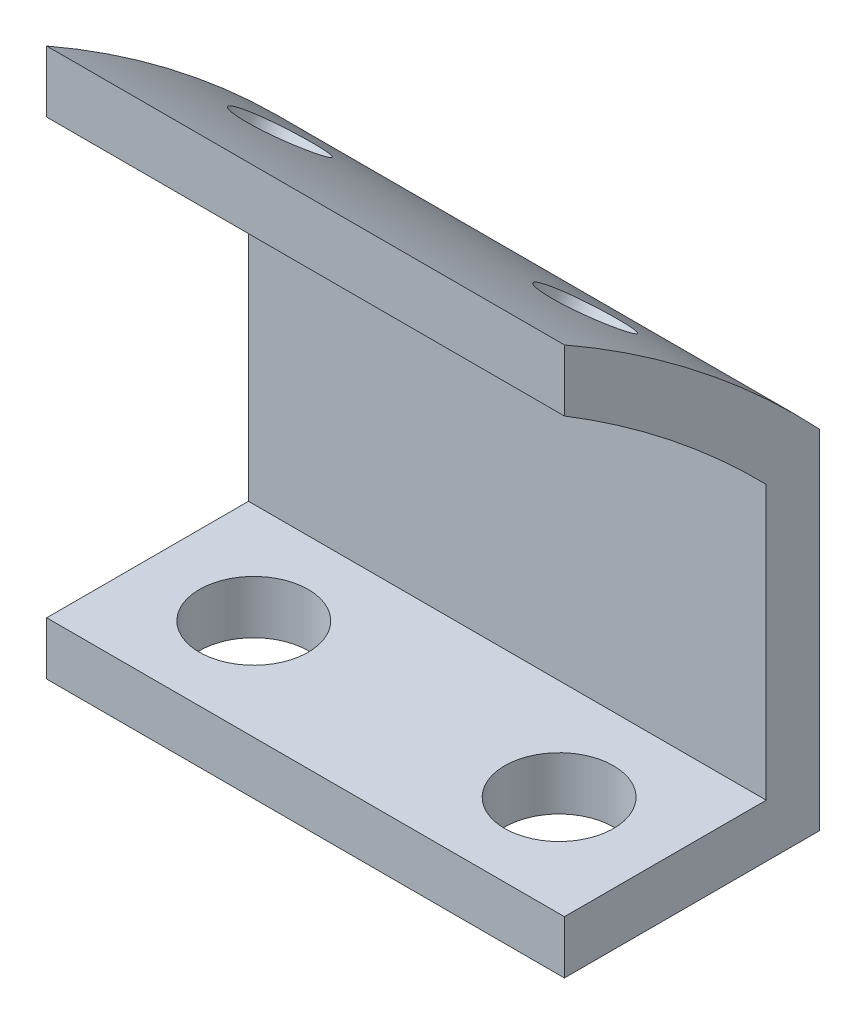
from build123d import *

# Parameters (mm, degrees)
BOSS_EXTRU_1_DEPTH           = 19.5
D_GAGEMENT_M3_51_D           = 4.1
D_GAGEMENT_M3_51_DEPTH       = 2
D_GAGEMENT_M2_51_D           = 3.1
D_GAGEMENT_M2_51_ON_FACE_2_D = 3.1


with BuildPart() as part:
    # Esquisse1 → Boss.-Extru.1 (new body)
    with BuildSketch(Plane(origin=(0, 0, 0), x_dir=(0, 0, -1), z_dir=(1, 0, 0))):
        with BuildLine():
            Line((29.85, 15), (29.85, 28.106538385))
            ThreePointArc((29.85, 28.106538385), (25.332375467, 32.237722519), (20.25, 35.650210378))
            Line((20.25, 35.650210378), (20.25, 33.330729065))
            ThreePointArc((20.25, 33.330729065), (24.238194894, 30.553394382), (27.85, 27.301602517))
            Line((27.85, 27.301602517), (27.85, 17))
            Line((27.85, 17), (20.25, 17))
            Line((20.25, 17), (20.25, 15))
            Line((20.25, 15), (29.85, 15))
        make_face()
    extrude(amount=BOSS_EXTRU_1_DEPTH)

    # Dégagement M3.51
    with Locations(Plane(origin=(0, 15, 0), x_dir=(-1, 0, 0), z_dir=(0, -1, 0))):
        with Locations((-15.5, 24.05), (-4, 24.05)):
            Hole(D_GAGEMENT_M3_51_D / 2, depth=D_GAGEMENT_M3_51_DEPTH)

    # Dégagement M2.51 (through all)
    with Locations(Plane(origin=(4, 32.466671627, -25.03827537), x_dir=(0, 0.610689643, 0.79187004), z_dir=(0, 0.79187004, -0.610689643))):
        with Locations((0, 0)):
            Hole(D_GAGEMENT_M2_51_D / 2)

    # Dégagement M2.51 on face 2 (through all)
    with Locations(Plane(origin=(15.5, 32.466671627, -25.03827537), x_dir=(0, 0.610689886, 0.791869852), z_dir=(0, 0.791869852, -0.610689886))):
        with Locations((0, 0)):
            Hole(D_GAGEMENT_M2_51_ON_FACE_2_D / 2)


solid = part.part
